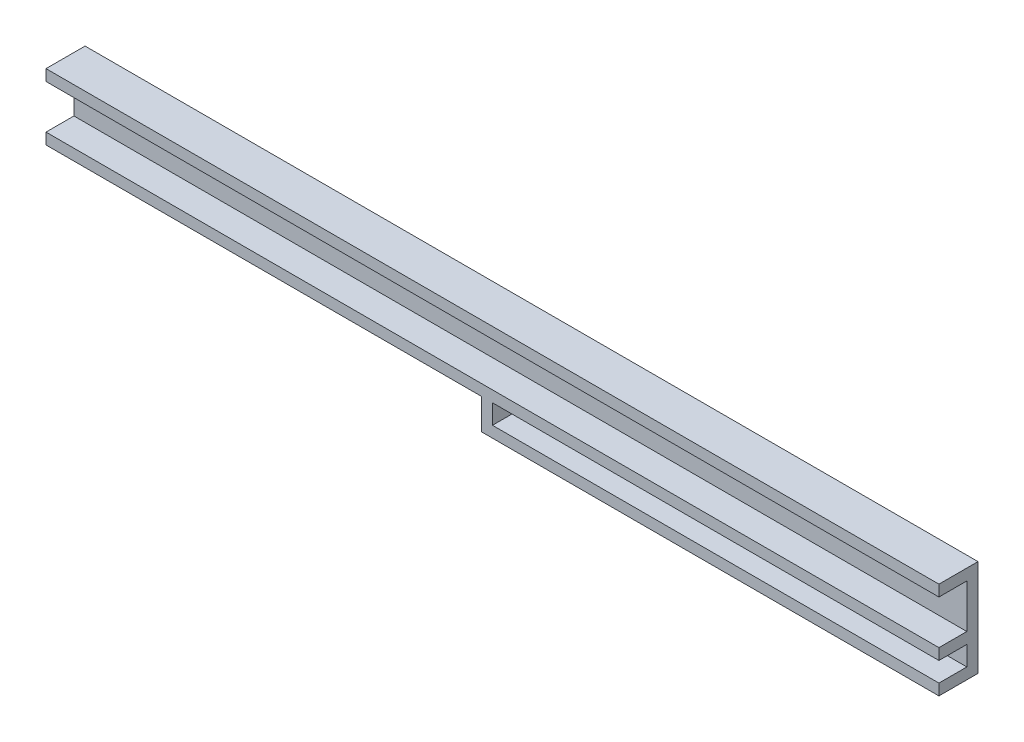
from build123d import *

# Parameters (mm, degrees)
ESBO_O1_W                  = 160
ESBO_O1_H                  = 2
RESSALTO_EXTRUS_O1_DEPTH   = 5
RESSALTO_EXTRUS_O1_2_DEPTH = 5
RESSALTO_EXTRUS_O2_DEPTH   = 2


with BuildPart() as part:
    # Esboço1 → Ressalto-extrusão1 (new body)
    with BuildSketch(Plane.XY):
        with Locations((40.767792431, 15.391143911)):
            Rectangle(ESBO_O1_W, ESBO_O1_H)
    extrude(amount=RESSALTO_EXTRUS_O1_DEPTH)



with BuildPart() as body_2:
    # Esboço1 → Ressalto-extrus_o1 2 (new body)
    with BuildSketch(Plane.XY):
        Polygon((120.767792431, 6.541143911), (-39.232207569, 6.541143911), (-39.232207569, 4.541143911), (38.767792431, 4.541143911), (38.767792431, -0.958856089), (120.767792431, -0.958856089), (120.767792431, 1.041143911), (40.767792431, 1.041143911), (40.767792431, 4.541143911), (120.767792431, 4.541143911), align=None)
    extrude(amount=RESSALTO_EXTRUS_O1_2_DEPTH)


with BuildPart() as part_1:
    add(part.part)

    add(body_2.part)  # Ressalto-extrusão2 merges body 2
    # Esboço1<3> → Ressalto-extrusão2 (add)
    with BuildSketch(Plane.XY):
        Polygon((-39.232207569, 16.391143911), (-39.232207569, 4.541143911), (38.767792431, 4.541143911), (38.767792431, -0.958856089), (120.767792431, -0.958856089), (120.767792431, 16.391143911), align=None)
    extrude(amount=-RESSALTO_EXTRUS_O2_DEPTH)


solid = part_1.part
